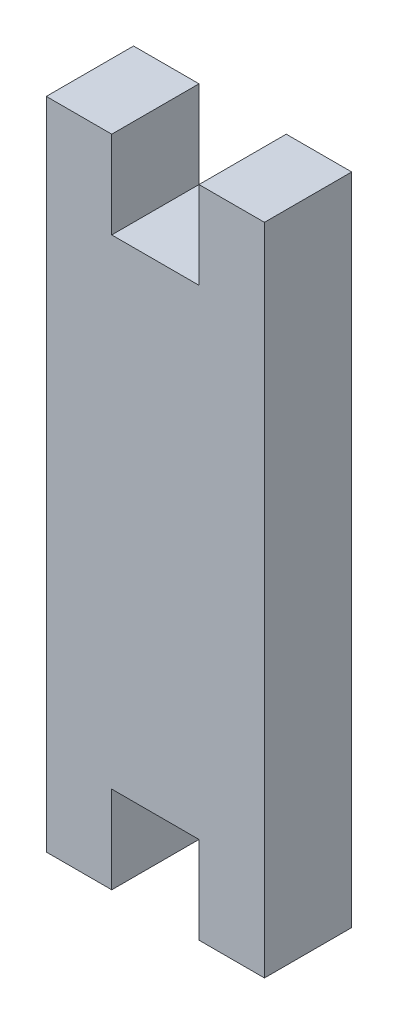
from build123d import *

# Parameters (mm, degrees)
SKETCH1_W           = 10
SKETCH1_H           = 30
BOSS_EXTRUDE1_DEPTH = 4
SKETCH2_W           = 4
SKETCH2_H           = 8
CUT_EXTRUDE1_DEPTH  = 5
SKETCH3_W           = 4
SKETCH3_H           = 8
CUT_EXTRUDE2_DEPTH  = 5


with BuildPart() as part:
    # Sketch1 → Boss-Extrude1 (new body)
    with BuildSketch(Plane.XY):
        with Locations((5, 15)):
            Rectangle(SKETCH1_W, SKETCH1_H)
    extrude(amount=BOSS_EXTRUDE1_DEPTH)

    # Sketch2 → Cut-Extrude1 (cut, through all)
    with BuildSketch(Plane.XY.offset(4)):
        with Locations((5, 0)):
            Rectangle(SKETCH2_W, SKETCH2_H)
    extrude(amount=-CUT_EXTRUDE1_DEPTH, mode=Mode.SUBTRACT)

    # Sketch3 → Cut-Extrude2 (cut, through all)
    with BuildSketch(Plane(origin=(0, 0, 0), x_dir=(-1, 0, 0), z_dir=(0, 0, -1))):
        with Locations((-5, 30)):
            Rectangle(SKETCH3_W, SKETCH3_H)
    extrude(amount=-CUT_EXTRUDE2_DEPTH, mode=Mode.SUBTRACT)


solid = part.part
